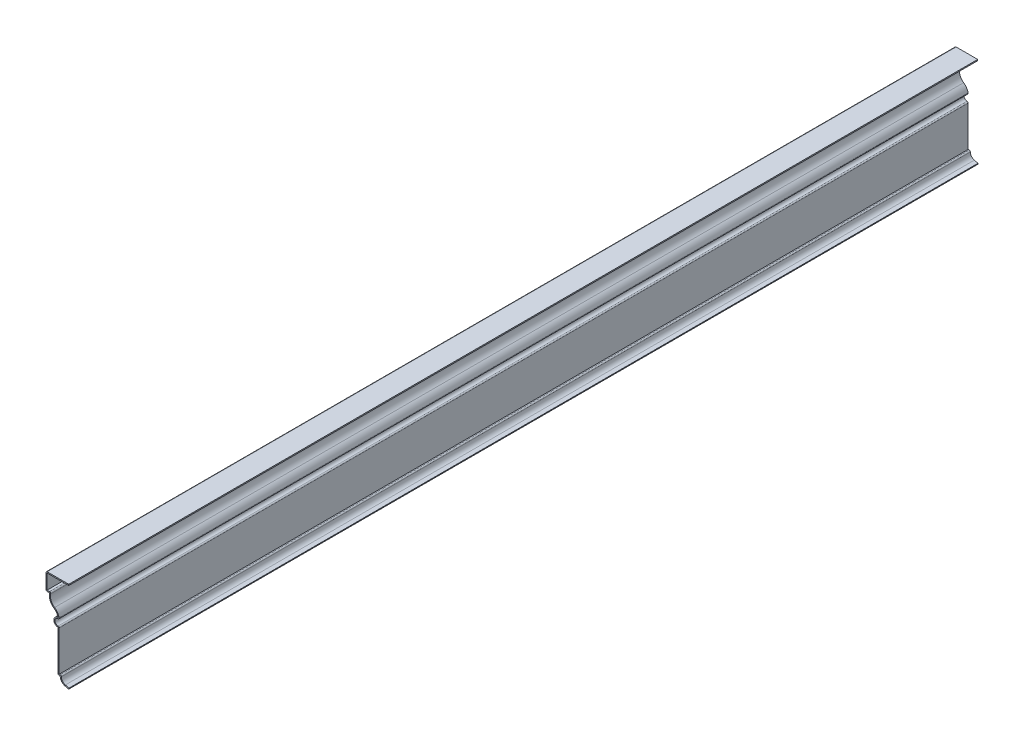
from build123d import *

# Parameters (mm, degrees)
EXTRUDE_THIN1_DEPTH = 1016
FILLET1_R           = 1.27


with BuildPart() as part:
    # Sketch1 → Extrude-Thin1 (new body)
    with BuildSketch(Plane.XY):
        with BuildLine():
            Line((0, 0), (-4.079695, 0.998592))
            ThreePointArc((-4.079695, 0.998592), (-8.001144, 3.52729), (-9.525, 7.9375))
            Line((-9.525, 7.9375), (-11.90625, 7.9375))
            Line((-11.90625, 7.9375), (-11.90625, 53.975))
            ThreePointArc((-11.90625, 53.975), (-16.66875, 58.7375), (-11.906249, 63.5))
            ThreePointArc((-11.906249, 63.5), (-13.570529, 67.254051), (-16.484535, 70.147372))
            ThreePointArc((-16.484535, 70.147372), (-20.860175, 75.589972), (-21.43125, 82.55))
            Line((-21.43125, 82.55), (-25.4, 82.55))
            Line((-25.4, 82.55), (-25.4, 101.6))
            Line((-25.4, 101.6), (0, 101.6))
            Line((0, 101.6), (0, 100.33))
            Line((0, 100.33), (-24.13, 100.33))
            Line((-24.13, 100.33), (-24.13, 83.82))
            Line((-24.13, 83.82), (-19.728013, 83.82))
            ThreePointArc((-19.728013, 83.82), (-19.950403, 76.819407), (-15.771635, 71.198406))
            ThreePointArc((-15.771635, 71.198406), (-12.006284, 67.154926), (-10.374537, 61.876196))
            ThreePointArc((-10.374537, 61.876196), (-15.395826, 58.880375), (-10.63625, 55.484093))
            Line((-10.63625, 55.484093), (-10.63625, 9.2075))
            Line((-10.63625, 9.2075), (-8.116059, 9.2075))
            ThreePointArc((-8.116059, 9.2075), (-7.369003, 4.835362), (-3.777749, 2.232175))
            Line((-3.777749, 2.232175), (0.301946, 1.233584))
            Line((0.301946, 1.233584), (0, 0))
        make_face()
    extrude(amount=-EXTRUDE_THIN1_DEPTH)

    # Fillet1
    fillet1_edges = [part.edges().sort_by_distance(p)[0] for p in [
        (-19.728013, 83.82, -508),
        (-10.374537, 61.876196, -508),
        (-10.63625, 55.484093, -508),
        (-8.116059, 9.2075, -508),
        (-11.90625, 7.9375, -508),
        (-25.4, 82.55, -508),
        (-25.4, 101.6, -508),
    ]]
    fillet(fillet1_edges, radius=FILLET1_R)


solid = part.part
